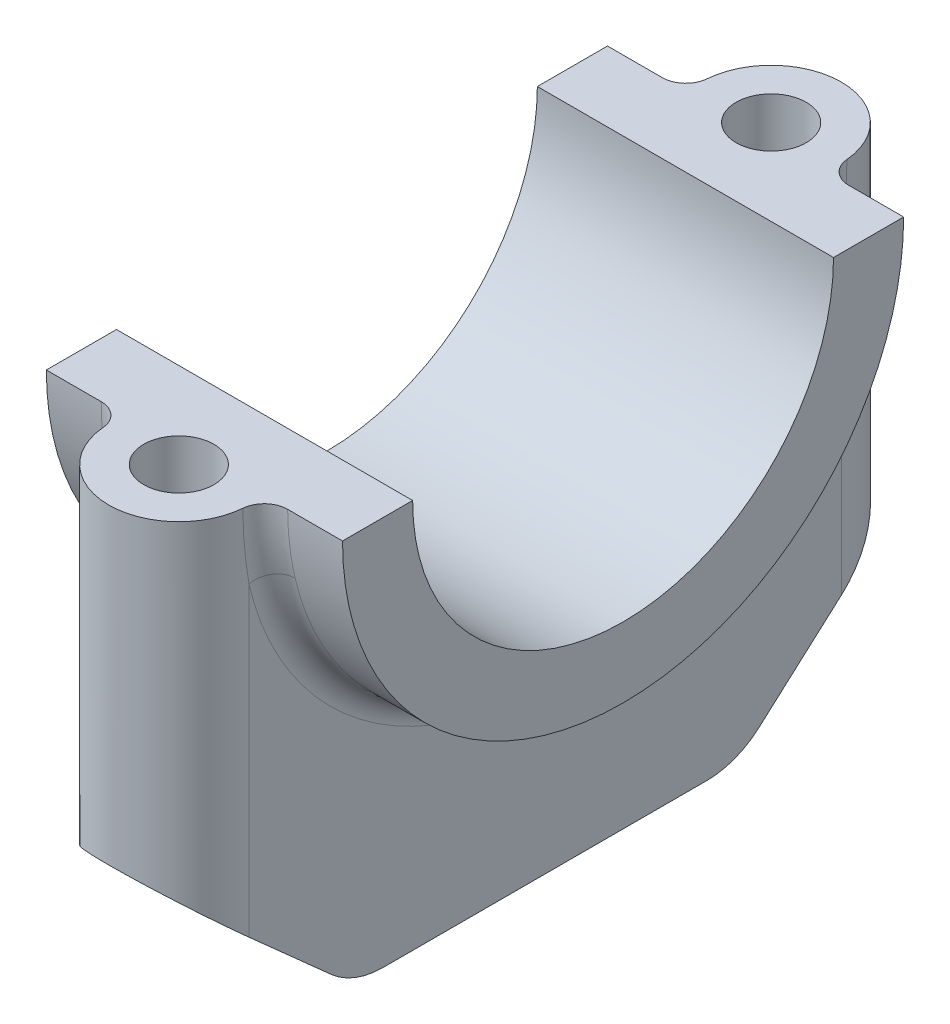
from build123d import *

# Parameters (mm, degrees)
BOSS_EXTRUDE1_DEPTH = 38
SKETCH2_R           = 9
SKETCH2_R_2         = 4.5
BOSS_EXTRUDE3_DEPTH = 60
SKETCH4_R           = 4.5
CUT_EXTRUDE1_DEPTH  = 61
CUT_EXTRUDE4_DEPTH  = 39
FILLET1_R           = 10
CUT_EXTRUDE5_DEPTH  = 10
SKETCH7_OUTSIDE_W   = 119.562
SKETCH7_OUTSIDE_H   = 85.562
SKETCH7_OUTSIDE_R   = 36
CUT_EXTRUDE6_DEPTH  = 10
FILLET2_R           = 3


with BuildPart() as part:
    # Sketch1 → Boss-Extrude1 (new body)
    with BuildSketch(Plane(origin=(0, 0, 0), x_dir=(0, 0, -1), z_dir=(1, 0, 0))):
        with BuildLine():
            Line((27, 30), (38, 30))
            Line((38, 30), (38, -30))
            Line((38, -30), (-38, -30))
            Line((-38, -30), (-38, 30))
            Line((-38, 30), (-27, 30))
            ThreePointArc((-27, 30), (0, 3), (27, 30))
        make_face()
    extrude(amount=BOSS_EXTRUDE1_DEPTH)

    # Sketch2 → Boss-Extrude3 (add, through all)
    with BuildSketch(Plane(origin=(0, 30, 0), x_dir=(1, 0, 0), z_dir=(0, 1, 0))):
        with Locations((19, -38)):
            Circle(SKETCH2_R)
        with Locations((19, -38)):
            Circle(SKETCH2_R_2, mode=Mode.SUBTRACT)
        with Locations((19, 38)):
            Circle(SKETCH2_R)
        with Locations((19, 38)):
            Circle(SKETCH2_R_2, mode=Mode.SUBTRACT)
    extrude(amount=-BOSS_EXTRUDE3_DEPTH)

    # Sketch4 → Cut-Extrude1 (cut, through all)
    with BuildSketch(Plane(origin=(0, 30, 0), x_dir=(1, 0, 0), z_dir=(0, 1, 0))):
        with Locations((19, -38)):
            Circle(SKETCH4_R)
        with Locations((19, 38)):
            Circle(SKETCH4_R)
    extrude(amount=-CUT_EXTRUDE1_DEPTH, mode=Mode.SUBTRACT)

    # Sketch5 → Cut-Extrude4 (cut, through all)
    with BuildSketch(Plane.ZY):
        Polygon((-47, -30), (-24.579488272, -30), (-47, -10), align=None)
        Polygon((47, -30), (24.579488272, -30), (47, -10), align=None)
    extrude(amount=-CUT_EXTRUDE4_DEPTH, mode=Mode.SUBTRACT)

    # Fillet1
    fillet1_edges = [part.edges().sort_by_distance(p)[0] for p in [
        (19, -30, 24.579488272),
        (19, -30, -24.579488272),
    ]]
    fillet(fillet1_edges, radius=FILLET1_R)

    # Sketch1_3 → Cut-Extrude5 (cut)
    with BuildSketch(Plane(origin=(0, 0, 0), x_dir=(0, 0, -1), z_dir=(1, 0, 0))):
        with BuildLine():
            Line((38, 30), (36, 30))
            ThreePointArc((36, 30), (0, -6), (-36, 30))
            Line((-36, 30), (-38, 30))
            Line((-38, 30), (-38, -30))
            Line((-38, -30), (38, -30))
            Line((38, -30), (38, 30))
        make_face()
    extrude(amount=CUT_EXTRUDE5_DEPTH, mode=Mode.SUBTRACT)

    # Sketch7 outside → Cut-Extrude6 (cut)
    with BuildSketch(Plane(origin=(38, 0, 0), x_dir=(0, 0, -1), z_dir=(1, 0, 0))):
        Rectangle(SKETCH7_OUTSIDE_W, SKETCH7_OUTSIDE_H)
        with Locations((0, 30)):
            Circle(SKETCH7_OUTSIDE_R, mode=Mode.SUBTRACT)
    extrude(amount=-CUT_EXTRUDE6_DEPTH, mode=Mode.SUBTRACT)

    # Fillet2
    fillet2_edges = [part.edges().sort_by_distance(p)[0] for p in [
        (10, -6, 0),
        (28, -6, 0),
    ]]
    fillet(fillet2_edges, radius=FILLET2_R)


solid = part.part
